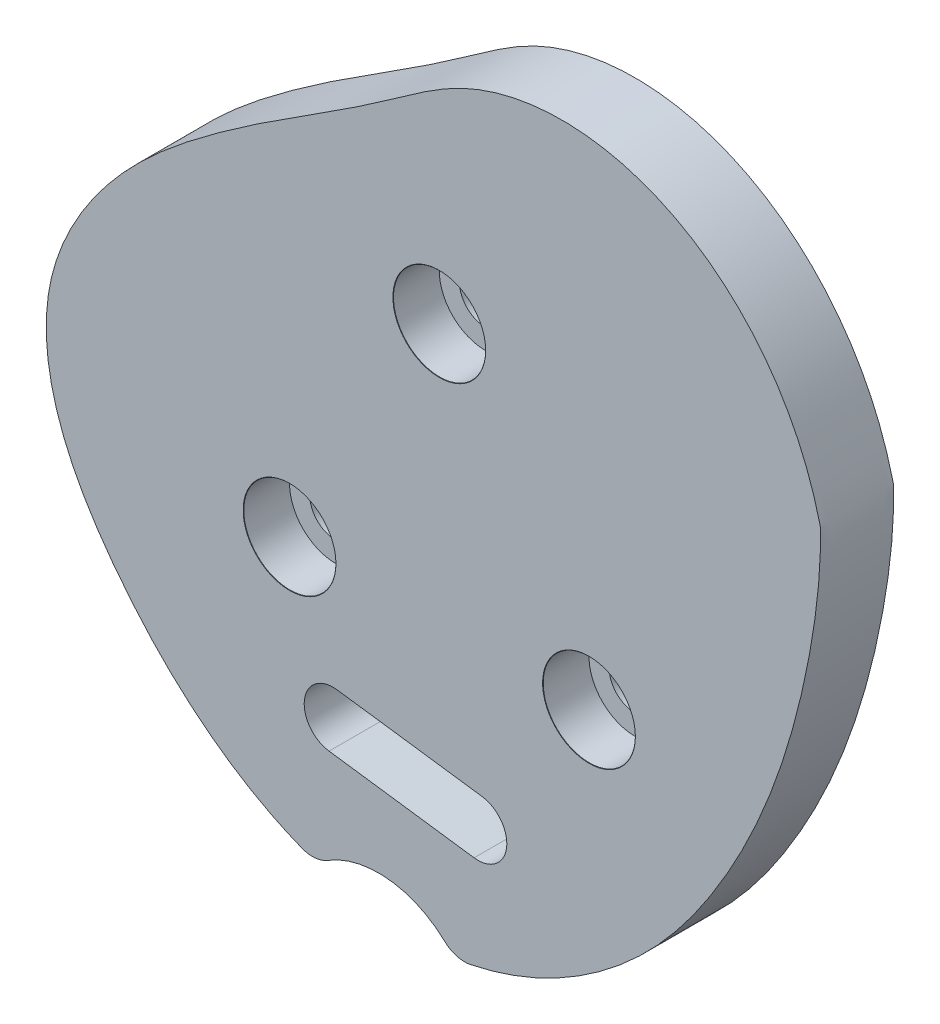
from build123d import *

# Parameters (mm, degrees)
BOSS_EXTRUDE1_DEPTH           = 3.175
CBORE_FOR_M4_SHCS1_AT_2_COUNT = 2
CBORE_FOR_M4_SHCS1_AT_2_PITCH = 25.980762114
CBORE_FOR_M4_SHCS1_AT_3_COUNT = 2
CBORE_FOR_M4_SHCS1_AT_3_PITCH = 25.980762114
CUT_EXTRUDE1_DEPTH            = 68.663769284
CUT_EXTRUDE1_DEPTH_BACK       = 68.663769284
FILLET1_R                     = 2.5


with BuildPart() as part:
    # Sketch1 → Boss-Extrude1 (new, symmetric)
    with BuildSketch(Plane.XY):
        with BuildLine():
            add(Edge.make_bspline(
                [(20.469276515, 0), (20.453926982, 0.12032637), (20.37906939, 0.354674879), (20.296830063, 0.708499092), (20.201433403, 1.058274137), (20.104513169, 1.405451482), (20.003039964, 1.749648928), (19.897882185, 2.090972241), (19.788868962, 2.429397518), (19.676103633, 2.764935406), (19.559614296, 3.097587319), (19.439446847, 3.427357), (19.315640263, 3.754247363), (19.18823323, 4.078261244), (19.057262426, 4.399401123), (18.922763033, 4.717669117), (18.784768655, 5.033066908), (18.643311395, 5.345595684), (18.498421896, 5.655256084), (18.350129388, 5.962048143), (18.198461741, 6.265971239), (18.043445514, 6.567024042), (17.885106009, 6.865204466), (17.723467325, 7.160509621), (17.558552411, 7.452935769), (17.390383125, 7.742478283), (17.218980293, 8.029131604), (17.044363762, 8.312889204), (16.866552466, 8.593743551), (16.685564483, 8.871686073), (16.501417094, 9.146707128), (16.314126853, 9.418795975), (16.123709641, 9.687940747), (15.930180735, 9.954128423), (15.73355487, 10.21734481), (15.533846304, 10.477574522), (15.331068884, 10.734800958), (15.125236108, 10.989006292), (14.916361195, 11.240171456), (14.704457148, 11.48827613), (14.48953682, 11.733298735), (14.271612982, 11.975216425), (14.050698387, 12.214005082), (13.826805837, 12.449639318), (13.599948249, 12.682092471), (13.37013872, 12.911336613), (13.137390595, 13.137342549), (12.901717528, 13.360079832), (12.66313355, 13.579516764), (12.42165313, 13.795620417), (12.177291245, 14.00835664), (11.930063436, 14.21769008), (11.679985874, 14.423584196), (11.427075422, 14.626001285), (11.171349697, 14.824902501), (10.912827125, 15.020247881), (10.651527006, 15.211996372), (10.387469571, 15.400105862), (10.120676038, 15.584533205), (9.851168668, 15.765234263), (9.578970821, 15.942163933), (9.30410701, 16.115276188), (9.026602952, 16.284524115), (8.746485624, 16.449859953), (8.463783305, 16.611235142), (8.178525632, 16.768600359), (7.890743643, 16.921905569), (7.600469825, 17.071100071), (7.307738154, 17.216132546), (7.012584144, 17.356951111), (6.71504488, 17.493503366), (6.415159063, 17.625736452), (6.112967045, 17.753597106), (5.808510864, 17.877031712), (5.501834279, 17.995986365), (5.192982801, 18.110406928), (4.882003722, 18.22023909), (4.568946147, 18.32542843), (4.253861014, 18.425920478), (3.936801123, 18.521660778), (3.617821156, 18.612594954), (3.296977698, 18.698668773), (2.974329252, 18.779828214), (2.649936258, 18.856019533), (2.323861105, 18.927189329), (1.996168144, 18.993284617), (1.666923695, 19.054252892), (1.336196056, 19.110042202), (1.004055505, 19.160601215), (0.670574308, 19.205879292), (0.335826712, 19.245826554), (-0.000111049, 19.280393959), (-0.337160764, 19.309533366), (-0.675242249, 19.33319761), (-1.014273357, 19.351340575), (-1.354169986, 19.36391726), (-1.694846096, 19.370883857), (-2.036213723, 19.372197815), (-2.378182996, 19.367817918), (-2.720662158, 19.357704349), (-3.06355759, 19.341818766), (-3.406773832, 19.320124369), (-3.750213613, 19.29258597), (-4.093777879, 19.259170061), (-4.437365826, 19.219844885), (-4.780874932, 19.174580501), (-5.124200991, 19.123348854), (-5.467238158, 19.066123837), (-5.809878982, 19.002881361), (-6.152014452, 18.933599416), (-6.493534041, 18.858258136), (-6.834325754, 18.776839862), (-7.174276174, 18.689329199), (-7.513270515, 18.595713085), (-7.851192674, 18.49598084), (-8.187925289, 18.39012423), (-8.52334979, 18.278137522), (-8.857346463, 18.160017536), (-9.18979451, 18.035763705), (-9.520572102, 17.905378106), (-9.849556485, 17.76886559), (-10.176623887, 17.626233534), (-10.501650192, 17.477492989), (-10.824508724, 17.322654615), (-11.145080224, 17.161743427), (-11.463230747, 16.994735948), (-11.779050897, 16.821987195), (-12.092717082, 16.643916451), (-12.40442328, 16.460901436), (-12.714391967, 16.273307346), (-13.022869092, 16.08147821), (-13.330124311, 15.885737879), (-13.636449754, 15.686388462), (-13.942159146, 15.48370949), (-14.247586785, 15.277956924), (-14.553086511, 15.069362251), (-14.859030639, 14.858131599), (-15.165808852, 14.64444489), (-15.473827068, 14.428455032), (-15.783506277, 14.210287148), (-16.095281345, 13.990037832), (-16.40959979, 13.767774461), (-16.72692054, 13.54353453), (-17.047712658, 13.317325034), (-17.372454053, 13.089121892), (-17.701630161, 12.858869404), (-18.035732622, 12.62647976), (-18.375257928, 12.391832591), (-18.720706063, 12.15477456), (-19.072579127, 11.915119006), (-19.43137995, 11.672645633), (-19.797610697, 11.427100253), (-20.171771452, 11.17819457), (-20.554358808, 10.925606023), (-20.94586444, 10.668977684), (-21.346773666, 10.407918194), (-21.757564012, 10.14200177), (-22.178703761, 9.870768248), (-22.6106505, 9.593723189), (-23.053849668, 9.310338029), (-23.508733094, 9.020050289), (-23.975717536, 8.722263829), (-24.455203223, 8.416349151), (-24.947572399, 8.101643764), (-25.453187868, 7.777452583), (-25.972391547, 7.443048392), (-26.505503025, 7.097672347), (-27.052818136, 6.74053453), (-27.614607536, 6.370814557), (-28.191115299, 5.98766223), (-28.782557525, 5.590198235), (-29.389120965, 5.1775149), (-30.01096166, 4.74867698), (-30.64820362, 4.302722541), (-31.300937436, 3.838663708), (-31.969219271, 3.355488182), (-32.653068482, 2.852157975), (-33.352355561, 2.327705554), (-34.066325533, 1.781561053), (-34.792156176, 1.21198818), (-35.526433511, 0.617909195), (-36.265587734, -0.001457622), (-37.006020345, -0.646671842), (-37.744112291, -1.318073183), (-38.476233993, -2.015780313), (-39.198754785, -2.739691012), (-39.908052424, -3.489482365), (-40.600522516, -4.264611377), (-41.272587879, -5.064315898), (-41.920707839, -5.8876159), (-42.541387444, -6.733315094), (-43.131186577, -7.600002901), (-43.686728957, -8.486056757), (-44.204711001, -9.389644786), (-44.681910487, -10.308728765), (-45.115195144, -11.241067557), (-45.501530481, -12.184220343), (-45.837989248, -13.135551967), (-46.121753439, -14.092231719), (-46.350171981, -15.051382919), (-46.520731563, -16.010470183), (-46.635259313, -16.966833368), (-46.695881182, -17.918707922), (-46.704758414, -18.864589252), (-46.664077675, -19.803116927), (-46.576039325, -20.733069832), (-46.442852564, -21.653366621), (-46.266728948, -22.563064411), (-46.04987654, -23.461357639), (-45.794494099, -24.347576614), (-45.502765451, -25.221185937), (-45.176853985, -26.081782762), (-44.818897277, -26.929094921), (-44.431001821, -27.762978927), (-44.015237852, -28.583417844), (-43.57363427, -29.390519034), (-43.108173634, -30.184511764), (-42.620787267, -30.965744674), (-42.113350378, -31.734683158), (-41.587677508, -32.491906358), (-41.045517213, -33.238104962), (-40.488554103, -33.974069902), (-39.918413965, -34.700676565), (-39.33481729, -35.417341816), (-38.737534614, -36.123431266), (-38.126368953, -36.818284488), (-37.501156774, -37.501216811), (-36.861768424, -38.171521432), (-36.208109378, -38.828470556), (-35.54012122, -39.471316853), (-34.857782619, -40.099294871), (-34.161110261, -40.711622507), (-33.450159719, -41.307502509), (-32.725026287, -41.886124006), (-31.985845748, -42.446664075), (-31.232795105, -42.98828933), (-30.466093242, -43.510157547), (-29.686001549, -44.011419305), (-28.892824481, -44.491219662), (-28.08691006, -44.948699845), (-27.268650333, -45.382998964), (-26.438481761, -45.793255749), (-25.596885557, -46.178610297), (-24.744387965, -46.538205845), (-23.881560483, -46.871190547), (-23.009020024, -47.176719273), (-22.127429019, -47.45395541), (-21.237495463, -47.702072683), (-20.339972901, -47.920256977), (-19.435660354, -48.10770816), (-18.525402181, -48.263641942), (-17.610087896, -48.387291641), (-16.690651874, -48.477910274), (-15.768073177, -48.534771472), (-14.84337466, -48.55717479), (-13.917624463, -48.544434556), (-12.991941631, -48.495930985), (-12.067628664, -48.41094298), (-11.146068248, -48.290046351), (-10.228680944, -48.134143741), (-9.316882792, -47.944122816), (-8.412028473, -47.72093942), (-7.515412754, -47.465590968), (-6.62826823, -47.179120315), (-5.751764231, -46.862611411), (-4.88700552, -46.517187103), (-4.03503117, -46.144006323), (-3.196813506, -45.744261393), (-2.373257143, -45.319175263), (-1.565198119, -44.86999873), (-0.773403127, -44.398007635), (0.001431168, -43.904500034), (0.758678706, -43.390793354), (1.497784521, -42.858221534), (2.218265124, -42.308132156), (2.919708798, -41.74188356), (3.601775788, -41.160841961), (4.2641984, -40.566378558), (4.906780999, -39.959866645), (5.529399907, -39.342678725), (6.132003211, -38.716183626), (6.714610467, -38.081743631), (7.277312313, -37.440711615), (7.82026998, -36.794428197), (8.343714715, -36.144218914), (8.847947092, -35.491391398), (9.333336294, -34.837232621), (9.800319062, -34.183006019), (10.24939942, -33.529949158), (10.681145161, -32.879269558), (11.096195715, -32.232147378), (11.49523197, -31.589707036), (11.879149859, -30.952992781), (12.248517048, -30.322552069), (12.603694342, -29.698556098), (12.945153788, -29.0811272), (13.273344314, -28.470359529), (13.588713491, -27.866335339), (13.891701075, -27.269121707), (14.182740239, -26.678771864), (14.462256803, -26.095325337), (14.730669009, -25.518808409), (14.988387177, -24.949234509), (15.2358134, -24.386604625), (15.473341258, -23.830907716), (15.701355534, -23.282121139), (15.920231962, -22.740211075), (16.130336972, -22.205132959), (16.332027463, -21.676831916), (16.525650586, -21.155243203), (16.711543541, -20.640292652), (16.890033391, -20.131897115), (17.061436892, -19.629964916), (17.226060335, -19.134396296), (17.384199405, -18.645083873), (17.536139055, -18.161913089), (17.682153396, -17.684762669), (17.822505599, -17.213505075), (17.957447815, -16.748006957), (18.087221108, -16.288129613), (18.212055405, -15.833729436), (18.332169455, -15.384658369), (18.447770812, -14.940764355), (18.559055824, -14.501891782), (18.666209639, -14.067881928), (18.769406229, -13.638573405), (18.868808423, -13.213802595), (18.964567955, -12.793404083), (19.056825528, -12.37721109), (19.14571089, -11.965055896), (19.231342923, -11.556770257), (19.313829749, -11.152185827), (19.393268841, -10.751134561), (19.469747157, -10.353449118), (19.543341277, -9.95896326), (19.614117561, -9.567512236), (19.682132311, -9.178933172), (19.747431952, -8.793065437), (19.810053221, -8.409751015), (19.870023364, -8.028834861), (19.927360353, -7.650165254), (19.982073105, -7.273594135), (20.034161718, -6.898977439), (20.083617711, -6.526175422), (20.130424277, -6.15505297), (20.174556549, -5.785479904), (20.215981868, -5.417331275), (20.254660065, -5.050487643), (20.290543747, -4.684835353), (20.323578606, -4.320266795), (20.353703685, -3.956680655), (20.380851823, -3.593982143), (20.404949486, -3.232083278), (20.425918912, -2.87090287), (20.443671673, -2.510367615), (20.458134208, -2.150408957), (20.469154396, -1.790975662), (20.476850973, -1.431987855), (20.480314085, -1.073508931), (20.482447125, -0.715105964), (20.47192834, -0.358233383), (20.484273463, -0.11756243), (20.469276515, 0)],
                knots=[0, 0, 0, 0, 0.001764203, 0.003519492, 0.005266096, 0.007004244, 0.008734164, 0.010456082, 0.01217022, 0.013876802, 0.015576046, 0.017268173, 0.018953398, 0.020631935, 0.022303998, 0.023969797, 0.025629542, 0.027283438, 0.02893169, 0.030574501, 0.032212071, 0.033844598, 0.035472279, 0.037095307, 0.038713875, 0.04032817, 0.041938381, 0.043544692, 0.045147285, 0.046746342, 0.048342038, 0.04993455, 0.05152405, 0.053110709, 0.054694695, 0.056276173, 0.057855307, 0.059432256, 0.061007179, 0.062580232, 0.064151567, 0.065721335, 0.067289683, 0.068856757, 0.070422701, 0.071987653, 0.073551752, 0.075115133, 0.076677929, 0.078240269, 0.079802281, 0.08136409, 0.082925818, 0.084487586, 0.08604951, 0.087611705, 0.089174283, 0.090737355, 0.092301027, 0.093865405, 0.09543059, 0.096996683, 0.09856378, 0.100131977, 0.101701366, 0.103272038, 0.10484408, 0.106417578, 0.107992614, 0.109569269, 0.111147622, 0.112727748, 0.114309722, 0.115893614, 0.117479494, 0.11906743, 0.120657485, 0.122249722, 0.123844203, 0.125440984, 0.127040123, 0.128641672, 0.130245685, 0.13185221, 0.133461296, 0.135072989, 0.136687331, 0.138304365, 0.139924131, 0.141546665, 0.143172005, 0.144800184, 0.146431233, 0.148065183, 0.149702063, 0.151341898, 0.152984714, 0.154630532, 0.156279374, 0.157931258, 0.159586203, 0.161244224, 0.162905335, 0.164569548, 0.166236874, 0.167907321, 0.169580897, 0.171257607, 0.172937454, 0.174620442, 0.176306572, 0.177995841, 0.179688248, 0.181383788, 0.183082456, 0.184784246, 0.186489147, 0.188197151, 0.189908245, 0.191622417, 0.193339652, 0.195059933, 0.196783244, 0.198509566, 0.200238878, 0.201971181, 0.203706635, 0.205445504, 0.2071881, 0.208934793, 0.210686019, 0.212442285, 0.214204179, 0.215972379, 0.217747655, 0.219530879, 0.221323028, 0.223125194, 0.224938584, 0.226764524, 0.228604465, 0.230459983, 0.232332781, 0.234224685, 0.236137652, 0.238073757, 0.2400352, 0.242024293, 0.244043462, 0.246095238, 0.248182252, 0.250307226, 0.252472967, 0.254682362, 0.256938364, 0.259243991, 0.261602312, 0.264016447, 0.266489554, 0.269024826, 0.271625481, 0.274294763, 0.277035933, 0.279852264, 0.282747038, 0.285723547, 0.288785083, 0.291934943, 0.295176421, 0.298512813, 0.30194741, 0.305483503, 0.309124377, 0.312873317, 0.316733603, 0.320708513, 0.324801324, 0.329015309, 0.333351662, 0.33780314, 0.342360129, 0.347012767, 0.351751024, 0.35656476, 0.361443788, 0.366377916, 0.371356998, 0.376370977, 0.381409928, 0.386464106, 0.391523993, 0.396580347, 0.401624264, 0.406647238, 0.411641236, 0.416598779, 0.421513038, 0.426377942, 0.431188305, 0.435939966, 0.440631828, 0.445270717, 0.449864684, 0.454421044, 0.458946377, 0.463446541, 0.467926691, 0.472391308, 0.476844238, 0.481288728, 0.48572748, 0.490162693, 0.494596121, 0.499029126, 0.50346273, 0.507897674, 0.512334472, 0.516773466, 0.521214882, 0.525658883, 0.530105625, 0.534555313, 0.539008153, 0.543464074, 0.5479229, 0.552384417, 0.556848379, 0.561314515, 0.565782528, 0.570252105, 0.57472292, 0.579194639, 0.583666924, 0.588139439, 0.592611855, 0.597083853, 0.601555132, 0.606025412, 0.610494439, 0.614961992, 0.619427887, 0.623891985, 0.628354194, 0.632814475, 0.637272853, 0.641729416, 0.646184326, 0.650637823, 0.655090233, 0.659541971, 0.663993554, 0.668445597, 0.672898832, 0.677354104, 0.681812384, 0.68627477, 0.690742499, 0.695216754, 0.699697325, 0.704183213, 0.708673274, 0.713166232, 0.71766069, 0.722155137, 0.726647962, 0.731137456, 0.735621826, 0.7400992, 0.744567632, 0.749025113, 0.753469575, 0.757898896, 0.762310907, 0.766703399, 0.771074124, 0.775420805, 0.779741136, 0.784032793, 0.788293433, 0.792520702, 0.796712241, 0.800865688, 0.804978687, 0.809048891, 0.813073968, 0.817051612, 0.820979544, 0.824855525, 0.82867736, 0.832442913, 0.836150111, 0.839796963, 0.843381676, 0.84690413, 0.850365453, 0.853766802, 0.857109335, 0.860394205, 0.863622561, 0.866795554, 0.86991433, 0.872980033, 0.875993807, 0.878956793, 0.881870128, 0.88473495, 0.887552392, 0.890323587, 0.893049665, 0.895731754, 0.898370977, 0.900968457, 0.903525314, 0.906042661, 0.908521612, 0.910963275, 0.913368751, 0.915739141, 0.918075538, 0.920379029, 0.922650695, 0.924891611, 0.927102843, 0.929285451, 0.931440483, 0.93356898, 0.935671971, 0.937750475, 0.939805498, 0.941838034, 0.943849063, 0.945839551, 0.947810449, 0.949762689, 0.95169719, 0.953614851, 0.955516554, 0.957403159, 0.959275508, 0.961134423, 0.962980703, 0.964815124, 0.966638443, 0.96845139, 0.970254675, 0.972048981, 0.973834969, 0.975613274, 0.977384508, 0.979149256, 0.980908081, 0.982661518, 0.984410078, 0.98615425, 0.987894493, 0.989631248, 0.991364926, 0.993095918, 0.994824589, 0.996551283, 0.998276321, 1, 1, 1, 1], degree=3))
        make_face()
    extrude(amount=BOSS_EXTRUDE1_DEPTH, both=True)

    # Sketch7 → CBORE for M4 SHCS1 (revolve, cut)
    with BuildSketch(Plane(origin=(-12.593900177, -1.272585975, 3.175), x_dir=(0, -1, 0), z_dir=(1, 0, 0))):
        Polygon((0, 0), (0, 6.35), (2.25, 6.35), (2.25, 4), (4, 4), (4, 0.025), (4.025, 0), align=None)
    cbore_for_m4_shcs1 = revolve(axis=Axis((-12.593900177, -1.272585975, 9.525), (0, 0, -1)), mode=Mode.SUBTRACT)

    # CBORE for M4 SHCS1 at 2: CBORE for M4 SHCS1 ×2
    with Locations(*[Vector(0.5000000000000265, -0.8660254037844234, 0) * (i * CBORE_FOR_M4_SHCS1_AT_2_PITCH) for i in range(1, CBORE_FOR_M4_SHCS1_AT_2_COUNT)]):
        add(cbore_for_m4_shcs1, mode=Mode.SUBTRACT)

    # CBORE for M4 SHCS1 at 3: CBORE for M4 SHCS1 ×2
    with Locations(*[Vector(-0.49999999999997374, -0.8660254037844538, 0) * (i * CBORE_FOR_M4_SHCS1_AT_3_PITCH) for i in range(1, CBORE_FOR_M4_SHCS1_AT_3_COUNT)]):
        add(cbore_for_m4_shcs1, mode=Mode.SUBTRACT)

    # Sketch8 → Cut-Extrude1 (cut, two sides)
    with BuildSketch(Plane.XY.offset(3.175)) as cut_extrude1_sk:
        with BuildLine():
            Line((-21.476274898, -33.202714717), (-8.89395292, -34.927583887))
            ThreePointArc((-8.89395292, -34.927583887), (-6.756659061, -37.743960097), (-9.573035271, -39.881253957))
            Line((-9.573035271, -39.881253957), (-22.155357248, -38.156384786))
            ThreePointArc((-22.155357248, -38.156384786), (-24.292651108, -35.340008576), (-21.476274898, -33.202714717))
        make_face()
        with BuildLine():
            Line((-24.717015232, -48.749713933), (-10.091760401, -50.412169461))
            ThreePointArc((-10.091760401, -50.412169461), (-16.908055463, -45.21451683), (-24.717015232, -48.749713933))
        make_face()
    extrude(amount=CUT_EXTRUDE1_DEPTH, mode=Mode.SUBTRACT)
    extrude(cut_extrude1_sk.sketch, amount=-CUT_EXTRUDE1_DEPTH_BACK, mode=Mode.SUBTRACT)

    # Fillet1
    fillet1_edges = [part.edges().sort_by_distance(p)[0] for p in [
        (-23.210337156, -47.103782694, 1.5874997),
        (-11.315796431, -48.309052102, -1.5875),
    ]]
    fillet(fillet1_edges, radius=FILLET1_R)


solid = part.part
